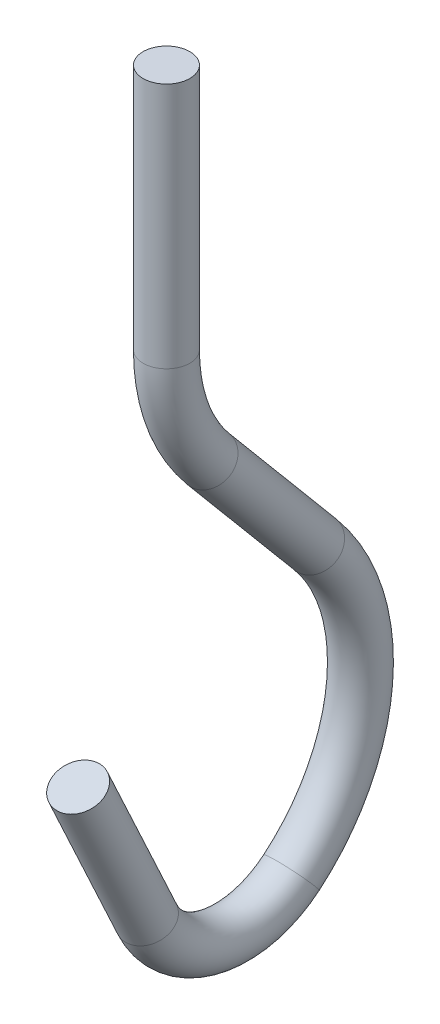
from build123d import *

# Parameters (mm, degrees)
SKETCH2_R = 0.635


with BuildPart() as part:
    # Sweep1: sweep along a path in Sketch1
    with BuildLine(Plane(origin=(0, 0, 0), x_dir=(0, 0, -1), z_dir=(1, 0, 0))) as sweep1_path:
        Line((-2.403997938, -15.816263763), (-0.530715835, -19.857293072))
        ThreePointArc((-0.530715835, -19.857293072), (1.218329614, -21.26591989), (3.400020828, -20.73336666))
        ThreePointArc((3.400020828, -20.73336666), (5.25921097, -17.161895627), (4.04844554, -13.321838283))
        Line((4.04844554, -13.321838283), (1.148017974, -9.865243311))
        ThreePointArc((1.148017974, -9.865243311), (0.295927809, -8.389379852), (0, -6.71108985))
        add(Edge.make_bspline(
            [(0, -6.71108985), (0, 0)],
            knots=[0, 0, 1, 1], degree=1))
    # Sketch2 → Sweep1 (sweep)
    with BuildSketch(Plane(origin=(0, 0, 0), x_dir=(1, 0, 0), z_dir=(0, 1, 0))):
        Circle(SKETCH2_R)
    sweep(path=sweep1_path.line)


solid = part.part
